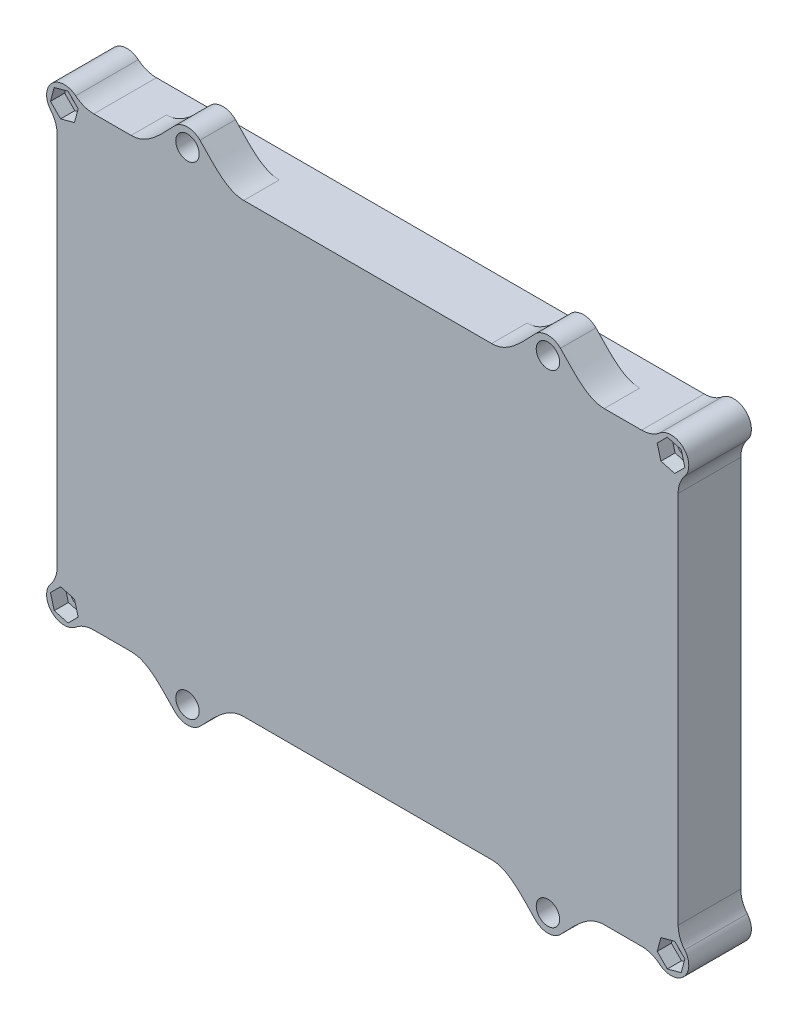
from build123d import *

# Parameters (mm, degrees)
BOSS_EXTRUDE1_START      = 2
SKETCH1_W                = 175
SKETCH1_H                = 126
BOSS_EXTRUDE1_DEPTH      = 2
SKETCH2_R                = 5
BOSS_EXTRUDE2_DEPTH      = 2
FILLET1_R                = 2
BOSS_EXTRUDE3_DEPTH      = 15.65
CUT_EXTRUDE_THIN1_DEPTH  = 2.25
SKETCH8_R                = 5
BOSS_EXTRUDE4_DEPTH      = 17.65
FILLET2_R                = 8
SKETCH9_R                = 1.5
BOSS_EXTRUDE5_DEPTH      = 2
M4_CLEARANCE_HOLE1_D     = 4.5
M4_CLEARANCE_HOLE1_DEPTH = 19.05
M4_CLEARANCE_HOLE1_TIP   = 1.351936393
CUT_EXTRUDE1_DEPTH       = 4
FILLET3_R                = 1
BOSS_EXTRUDE6_DEPTH      = 10
M6_CLEARANCE_HOLE2_D     = 6.6
M6_CLEARANCE_HOLE2_DEPTH = 19.05
M6_CLEARANCE_HOLE2_TIP   = 1.982840043


with BuildPart() as part:
    # Sketch1 → Boss-Extrude1 (new body)
    with BuildSketch(Plane.XY.offset(BOSS_EXTRUDE1_START)):
        with Locations((-70.5, 46)):
            Rectangle(SKETCH1_W, SKETCH1_H)
    extrude(amount=BOSS_EXTRUDE1_DEPTH)

    # Sketch2 → Boss-Extrude2 (add)
    with BuildSketch(Plane(origin=(0, 0, 2), x_dir=(-1, 0, 0), z_dir=(0, 0, -1))):
        Circle(SKETCH2_R)
        with Locations((69.5, 63.5)):
            Circle(SKETCH2_R)
        with Locations((0, 92)):
            Circle(SKETCH2_R)
        with Locations((141, 92)):
            Circle(SKETCH2_R)
        with Locations((141, 0)):
            Circle(SKETCH2_R)
    extrude(amount=BOSS_EXTRUDE2_DEPTH)

    # Fillet1
    fillet1_edges = [part.edges().sort_by_distance(p)[0] for p in [
        (-158, 109, 3),
        (17, 109, 3),
        (17, -17, 3),
        (-158, -17, 3),
    ]]
    fillet(fillet1_edges, radius=FILLET1_R)

    # Sketch3 → Boss-Extrude3 (add)
    with BuildSketch(Plane(origin=(0, 0, 2), x_dir=(-1, 0, 0), z_dir=(0, 0, -1))):
        with BuildLine():
            Line((-15, 109), (156, 109))
            ThreePointArc((156, 109), (157.414213562, 108.414213562), (158, 107))
            Line((158, 107), (158, -15))
            ThreePointArc((158, -15), (157.414213562, -16.414213562), (156, -17))
            Line((156, -17), (-15, -17))
            ThreePointArc((-15, -17), (-16.414213562, -16.414213562), (-17, -15))
            Line((-17, -15), (-17, 107))
            ThreePointArc((-17, 107), (-16.414213562, 108.414213562), (-15, 109))
        make_face()
        with BuildLine():
            Line((-3, 102), (144, 102))
            ThreePointArc((144, 102), (148.949747468, 99.949747468), (151, 95))
            Line((151, 95), (151, -3))
            ThreePointArc((151, -3), (148.949747468, -7.949747468), (144, -10))
            Line((144, -10), (-3, -10))
            ThreePointArc((-3, -10), (-7.949747468, -7.949747468), (-10, -3))
            Line((-10, -3), (-10, 95))
            ThreePointArc((-10, 95), (-7.949747468, 99.949747468), (-3, 102))
        make_face(mode=Mode.SUBTRACT)
    extrude(amount=BOSS_EXTRUDE3_DEPTH)

    # Sketch5 → Cut-Extrude-Thin1 (cut)
    with BuildSketch(Plane(origin=(0, 0, -13.65), x_dir=(-1, 0, 0), z_dir=(0, 0, -1))):
        with BuildLine():
            Line((-3, 107), (144, 107))
            ThreePointArc((144, 107), (152.485281374, 103.485281374), (156, 95))
            Line((156, 95), (156, -3))
            ThreePointArc((156, -3), (152.485281374, -11.485281374), (144, -15))
            Line((144, -15), (-3, -15))
            ThreePointArc((-3, -15), (-11.485281374, -11.485281374), (-15, -3))
            Line((-15, -3), (-15, 95))
            ThreePointArc((-15, 95), (-11.485281374, 103.485281374), (-3, 107))
        make_face()
        with BuildLine():
            Line((-3, 104), (144, 104))
            ThreePointArc((144, 104), (150.363961031, 101.363961031), (153, 95))
            Line((153, 95), (153, -3))
            ThreePointArc((153, -3), (150.363961031, -9.363961031), (144, -12))
            Line((144, -12), (-3, -12))
            ThreePointArc((-3, -12), (-9.363961031, -9.363961031), (-12, -3))
            Line((-12, -3), (-12, 95))
            ThreePointArc((-12, 95), (-9.363961031, 101.363961031), (-3, 104))
        make_face(mode=Mode.SUBTRACT)
    extrude(amount=-CUT_EXTRUDE_THIN1_DEPTH, mode=Mode.SUBTRACT)

    # Sketch8 → Boss-Extrude4 (add)
    with BuildSketch(Plane(origin=(0, 0, -13.65), x_dir=(-1, 0, 0), z_dir=(0, 0, -1))):
        with Locations((156, 107)):
            Circle(SKETCH8_R)
        with Locations((156, -15)):
            Circle(SKETCH8_R)
        with Locations((-15, -15)):
            Circle(SKETCH8_R)
        with Locations((-15, 107)):
            Circle(SKETCH8_R)
    extrude(amount=-BOSS_EXTRUDE4_DEPTH)

    # Fillet2
    fillet2_edges = [part.edges().sort_by_distance(p)[0] for p in [
        (-151.417424305, 109, -4.825),
        (-158, 102.417424305, -4.825),
        (-158, -10.417424305, -4.825),
        (-151.417424305, -17, -4.825),
        (10.417424305, -17, -4.825),
        (17, -10.417424305, -4.825),
        (17, 102.417424305, -4.825),
        (10.417424305, 109, -4.825),
    ]]
    fillet(fillet2_edges, radius=FILLET2_R)

    # Sketch9 → Boss-Extrude5 (add)
    with BuildSketch(Plane(origin=(0, 0, 0), x_dir=(-1, 0, 0), z_dir=(0, 0, -1))):
        with Locations((0, 92)):
            Circle(SKETCH9_R)
        Circle(SKETCH9_R)
        with Locations((69.5, 63.5)):
            Circle(SKETCH9_R)
        with Locations((141, 92)):
            Circle(SKETCH9_R)
        with Locations((141, 0)):
            Circle(SKETCH9_R)
    extrude(amount=BOSS_EXTRUDE5_DEPTH)

    # M4 Clearance Hole1
    with Locations(Plane(origin=(0, 0, -13.65), x_dir=(-1, 0, 0), z_dir=(0, 0, -1))):
        with Locations((-15, 107), (-15, -15), (156, -15), (156, 107)):
            Hole(M4_CLEARANCE_HOLE1_D / 2, depth=M4_CLEARANCE_HOLE1_DEPTH)
            with Locations((0, 0, -(M4_CLEARANCE_HOLE1_DEPTH + M4_CLEARANCE_HOLE1_TIP / 2))):  # 118° drill point
                Cone(0, M4_CLEARANCE_HOLE1_D / 2, M4_CLEARANCE_HOLE1_TIP, mode=Mode.SUBTRACT)

    # Sketch12 → Cut-Extrude1 (cut)
    with BuildSketch(Plane.XY.offset(4)):
        Polygon((17.857738033, -17.857738033), (18.903742751, -13.953995282), (16.046004718, -11.096257249), (12.142261967, -12.142261967), (11.096257249, -16.046004718), (13.953995282, -18.903742751), align=None)
        Polygon((17.857738033, 109.857738033), (13.953995282, 110.903742751), (11.096257249, 108.046004718), (12.142261967, 104.142261967), (16.046004718, 103.096257249), (18.903742751, 105.953995282), align=None)
        Polygon((-158.857738033, 109.857738033), (-159.903742751, 105.953995282), (-157.046004718, 103.096257249), (-153.142261967, 104.142261967), (-152.096257249, 108.046004718), (-154.953995282, 110.903742751), align=None)
        Polygon((-153.142261967, -12.142261967), (-157.046004718, -11.096257249), (-159.903742751, -13.953995282), (-158.857738033, -17.857738033), (-154.953995282, -18.903742751), (-152.096257249, -16.046004718), align=None)
    extrude(amount=-CUT_EXTRUDE1_DEPTH, mode=Mode.SUBTRACT)

    # Fillet3
    fillet3_edges = [part.edges().sort_by_distance(p)[0] for p in [
        (5, 0, 2),
        (-64.5, 63.5, 2),
        (5, 92, 2),
        (-136, 92, 2),
        (-136, 0, 2),
        (-148.949747468, 99.949747468, 2),
        (-70.5, 102, 2),
        (7.949747468, 99.949747468, 2),
        (10, 46, 2),
        (7.949747468, -7.949747468, 2),
        (-70.5, -10, 2),
        (-148.949747468, -7.949747468, 2),
        (-151, 46, 2),
    ]]
    fillet(fillet3_edges, radius=FILLET3_R)

    # Sketch13 → Boss-Extrude6 (add)
    with BuildSketch(Plane.XY.offset(4)):
        with BuildLine():
            Line((-105.425, -17), (-137.175, -17))
            add(Edge.make_bspline(
                [(-137.175, -17), (-132.173691698, -17), (-128.371992921, -21.999074891), (-124.835533906, -25.535533906)],
                knots=[0, 0, 0, 0, 1, 1, 1, 1], degree=3))
            ThreePointArc((-124.835533906, -25.535533906), (-121.3, -27), (-117.764466094, -25.535533906))
            add(Edge.make_bspline(
                [(-105.425, -17), (-110.426308302, -17), (-114.228007079, -21.999074891), (-117.764466094, -25.535533906)],
                knots=[0, 0, 0, 0, 1, 1, 1, 1], degree=3))
        make_face()
        with BuildLine():
            Line((-35.575, -17), (-3.825, -17))
            add(Edge.make_bspline(
                [(-3.825, -17), (-8.826308302, -17), (-12.628007079, -21.999074891), (-16.164466094, -25.535533906)],
                knots=[0, 0, 0, 0, 1, 1, 1, 1], degree=3))
            ThreePointArc((-16.164466094, -25.535533906), (-19.7, -27), (-23.235533906, -25.535533906))
            add(Edge.make_bspline(
                [(-35.575, -17), (-30.573691698, -17), (-26.771992921, -21.999074891), (-23.235533906, -25.535533906)],
                knots=[0, 0, 0, 0, 1, 1, 1, 1], degree=3))
        make_face()
        with BuildLine():
            Line((-35.575, 109), (-3.825, 109))
            add(Edge.make_bspline(
                [(-3.825, 109), (-8.826308302, 109), (-12.628007079, 113.999074891), (-16.164466094, 117.535533906)],
                knots=[0, 0, 0, 0, 1, 1, 1, 1], degree=3))
            ThreePointArc((-16.164466094, 117.535533906), (-19.7, 119), (-23.235533906, 117.535533906))
            add(Edge.make_bspline(
                [(-35.575, 109), (-30.573691698, 109), (-26.771992921, 113.999074891), (-23.235533906, 117.535533906)],
                knots=[0, 0, 0, 0, 1, 1, 1, 1], degree=3))
        make_face()
        with BuildLine():
            Line((-105.425, 109), (-137.175, 109))
            add(Edge.make_bspline(
                [(-137.175, 109), (-132.173691698, 109), (-128.371992921, 113.999074891), (-124.835533906, 117.535533906)],
                knots=[0, 0, 0, 0, 1, 1, 1, 1], degree=3))
            ThreePointArc((-124.835533906, 117.535533906), (-121.3, 119), (-117.764466094, 117.535533906))
            add(Edge.make_bspline(
                [(-105.425, 109), (-110.426308302, 109), (-114.228007079, 113.999074891), (-117.764466094, 117.535533906)],
                knots=[0, 0, 0, 0, 1, 1, 1, 1], degree=3))
        make_face()
    extrude(amount=-BOSS_EXTRUDE6_DEPTH)

    # M6 Clearance Hole2
    with Locations(Plane(origin=(0, 0, -6), x_dir=(-1, 0, 0), z_dir=(0, 0, -1))):
        with Locations((19.7, 114), (121.3, 114), (121.3, -22), (19.7, -22)):
            Hole(M6_CLEARANCE_HOLE2_D / 2, depth=M6_CLEARANCE_HOLE2_DEPTH)
            with Locations((0, 0, -(M6_CLEARANCE_HOLE2_DEPTH + M6_CLEARANCE_HOLE2_TIP / 2))):  # 118° drill point
                Cone(0, M6_CLEARANCE_HOLE2_D / 2, M6_CLEARANCE_HOLE2_TIP, mode=Mode.SUBTRACT)


solid = part.part
